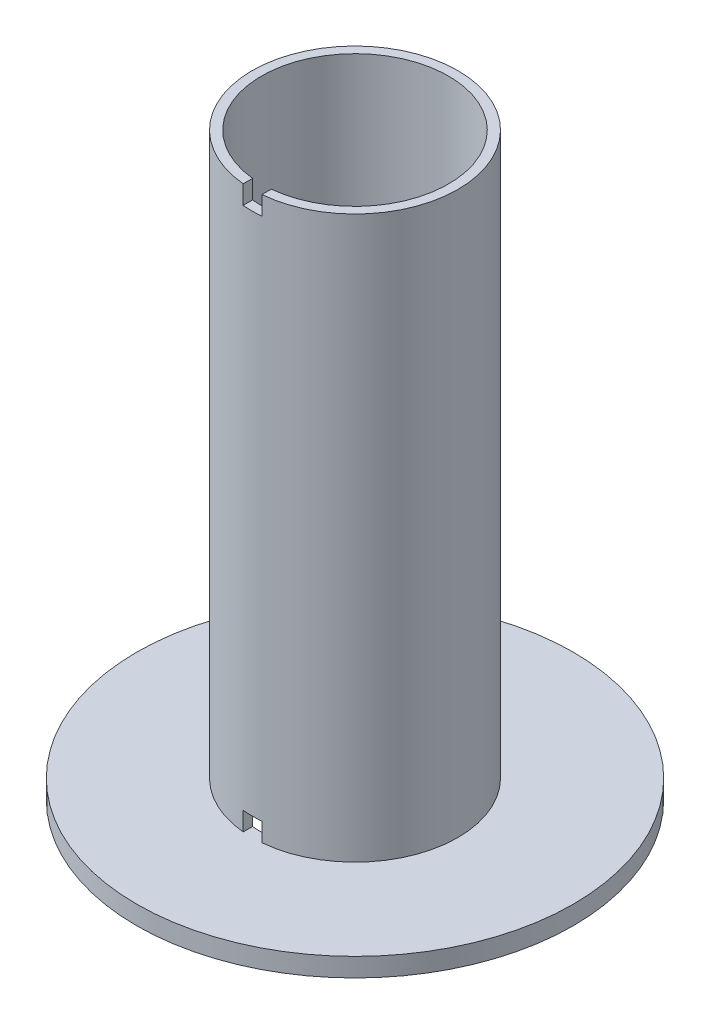
from build123d import *

# Parameters (mm, degrees)
SKETCH1_R           = 88.9
SKETCH1_R_2         = 38.1
BOSS_EXTRUDE1_DEPTH = 7.62
SKETCH2_R           = 41.91
SKETCH2_R_2         = 38.1
BOSS_EXTRUDE2_DEPTH = 228.6
SKETCH3_W           = 7.62
SKETCH3_H           = 7.62
CUT_EXTRUDE1_DEPTH  = 89.9


with BuildPart() as part:
    # Sketch1 → Boss-Extrude1 (new body)
    with BuildSketch(Plane(origin=(0, 0, 0), x_dir=(1, 0, 0), z_dir=(0, 1, 0))):
        Circle(SKETCH1_R)
        Circle(SKETCH1_R_2, mode=Mode.SUBTRACT)
    extrude(amount=BOSS_EXTRUDE1_DEPTH)

    # Sketch2 → Boss-Extrude2 (add)
    with BuildSketch(Plane(origin=(0, 7.62, 0), x_dir=(1, 0, 0), z_dir=(0, 1, 0))):
        Circle(SKETCH2_R)
        Circle(SKETCH2_R_2, mode=Mode.SUBTRACT)
    extrude(amount=BOSS_EXTRUDE2_DEPTH)

    # Sketch3 → Cut-Extrude1 (cut, through all)
    with BuildSketch(Plane.XY):
        with Locations((0, 11.43)):
            Rectangle(SKETCH3_W, SKETCH3_H)
        with Locations((0, 232.41)):
            Rectangle(SKETCH3_W, SKETCH3_H)
    extrude(amount=CUT_EXTRUDE1_DEPTH, mode=Mode.SUBTRACT)


solid = part.part
